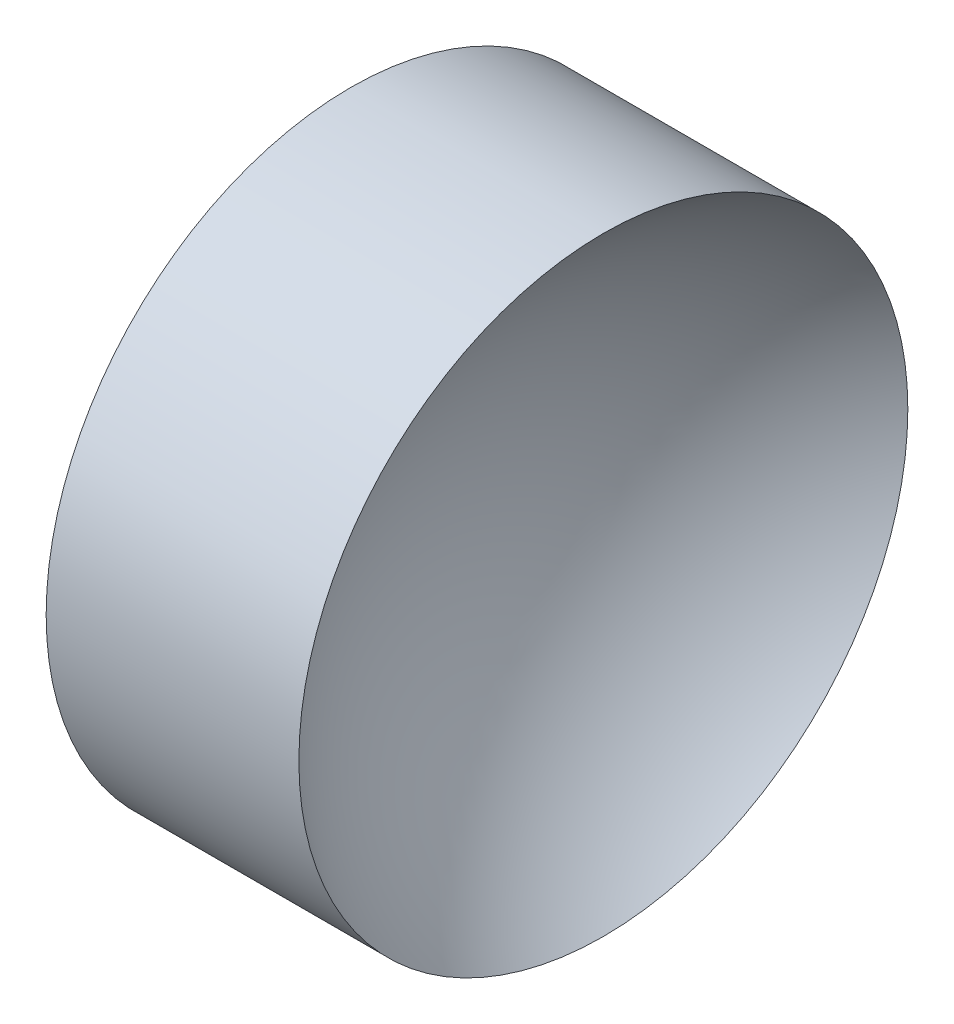
from build123d import *


with BuildPart() as part:
    # 草图1 → 旋转1 (revolve)
    with BuildSketch(Plane.XY, mode=Mode.PRIVATE) as revolve_1_sk:
        with BuildLine():
            Line((47.744711016, 28.477595635), (47.744711016, 34.827595635))
            Line((47.744711016, 34.827595635), (53.015086307, 34.827595635))
            ThreePointArc((53.015086307, 34.827595635), (50.610337478, 32.048934828), (49.744711016, 28.477595635))
            Line((49.744711016, 28.477595635), (47.744711016, 28.477595635))
        make_face()
    revolve(revolve_1_sk.sketch.rotate(Axis((44.782091903, 28.477595635, 0), (1, 0, 0)), 180), axis=Axis((44.782091903, 28.477595635, 0), (1, 0, 0)))  # turned: the seam where the file's is


solid = part.part
